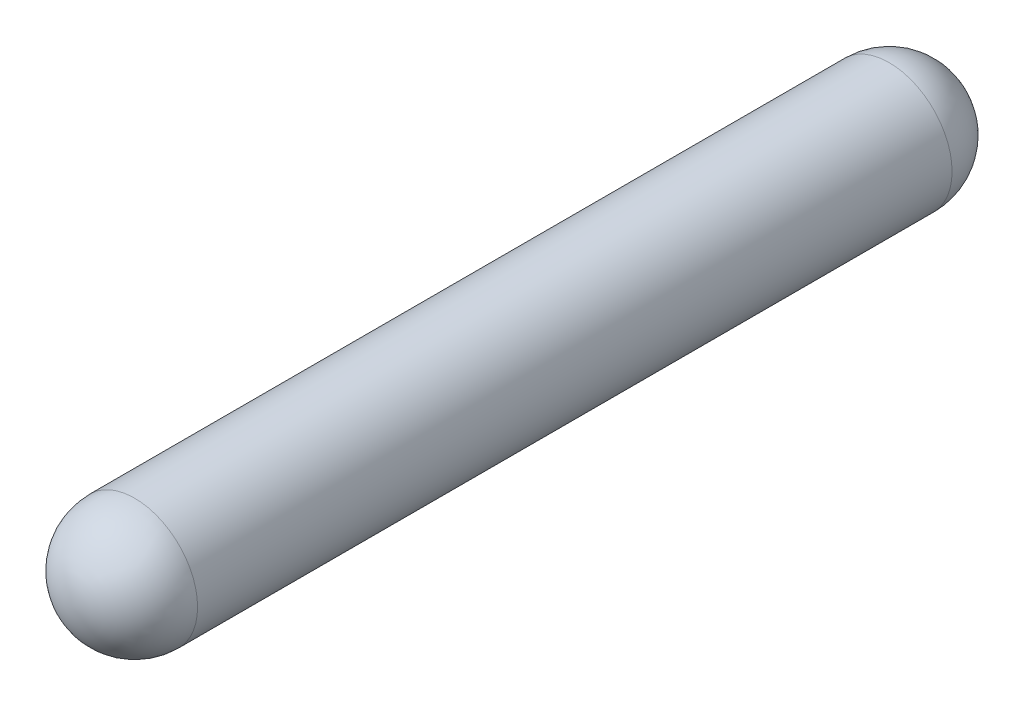
from build123d import *


with BuildPart() as part:
    # Sketch1 → Revolve1 (revolve)
    with BuildSketch(Plane(origin=(0, 0, 0), x_dir=(1, 0, 0), z_dir=(0, 1, 0))):
        with BuildLine():
            Line((0, 0), (0, 35))
            ThreePointArc((0, 35), (-3.535533906, 33.535533906), (-5, 30))
            Line((-5, 30), (-5, 0))
            Line((-5, 0), (0, 0))
        make_face()
    revolve1 = revolve(axis=Axis((0, 0, 0), (0, 0, -1)))

    # Mirror1: Revolve1 across plane
    add(revolve1.mirror(Plane.XY))


solid = part.part
